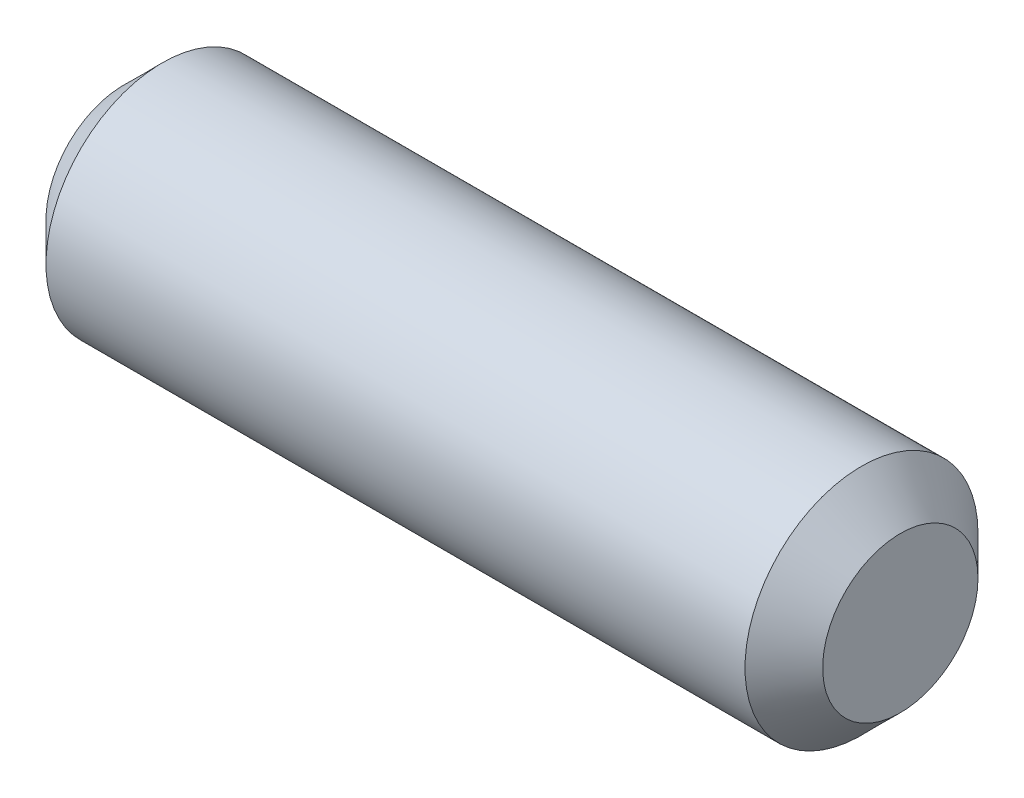
from build123d import *

# Parameters (mm, degrees)
ESQUISSE1_R     = 1.5
AXE_DEPTH       = 5
CHANFREIN1_SIZE = 0.5


with BuildPart() as part:
    # Esquisse1 → AXE (new body, symmetric)
    with BuildSketch(Plane(origin=(0, 0, 0), x_dir=(0, 0, -1), z_dir=(1, 0, 0))):
        Circle(ESQUISSE1_R)
    extrude(amount=AXE_DEPTH, both=True)

    # Chanfrein1
    chanfrein1_edges = [part.edges().sort_by_distance(p)[0] for p in [
        (-5, 0, 1.5),
        (5, 0, 1.5),
    ]]
    chamfer(chanfrein1_edges, length=CHANFREIN1_SIZE)


solid = part.part
